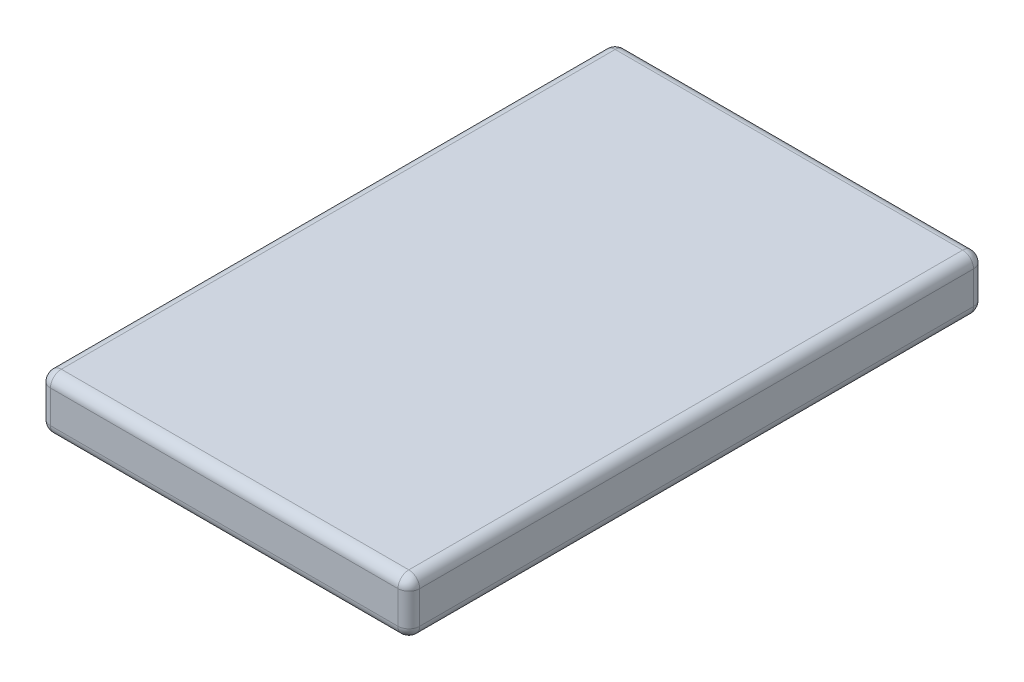
from build123d import *

# Parameters (mm, degrees)
SKETCH1_W           = 34
SKETCH1_H           = 53
BOSS_EXTRUDE1_DEPTH = 5
FILLET1_R           = 1
FILLET2_R           = 1


with BuildPart() as part:
    # Sketch1 → Boss-Extrude1 (new body)
    with BuildSketch(Plane(origin=(0, 0, 0), x_dir=(1, 0, 0), z_dir=(0, 1, 0))):
        Rectangle(SKETCH1_W, SKETCH1_H)
    extrude(amount=BOSS_EXTRUDE1_DEPTH)

    # Fillet1
    fillet1_edges = [part.edges().sort_by_distance(p)[0] for p in [
        (-17, 5, 0),
        (17, 5, 0),
        (-17, 0, 0),
        (17, 0, 0),
    ]]
    fillet(fillet1_edges, radius=FILLET1_R)

    # Fillet2
    fillet2_edges = [part.edges().sort_by_distance(p)[0] for p in [
        (-17, 2.5, 26.5),
        (-17, 2.5, -26.5),
        (0, 0, 26.5),
        (17, 2.5, 26.5),
        (0, 5, 26.5),
        (16.707106781, 4.707106781, 26.5),
        (16.707106781, 0.292893219, 26.5),
        (-16.707106781, 4.707106781, 26.5),
        (-16.707106781, 0.292893219, 26.5),
        (0, 0, -26.5),
        (0, 5, -26.5),
        (17, 2.5, -26.5),
        (16.707106781, 4.707106781, -26.5),
        (16.707106781, 0.292893219, -26.5),
        (-16.707106781, 4.707106781, -26.5),
        (-16.707106781, 0.292893219, -26.5),
    ]]
    fillet(fillet2_edges, radius=FILLET2_R)


solid = part.part
